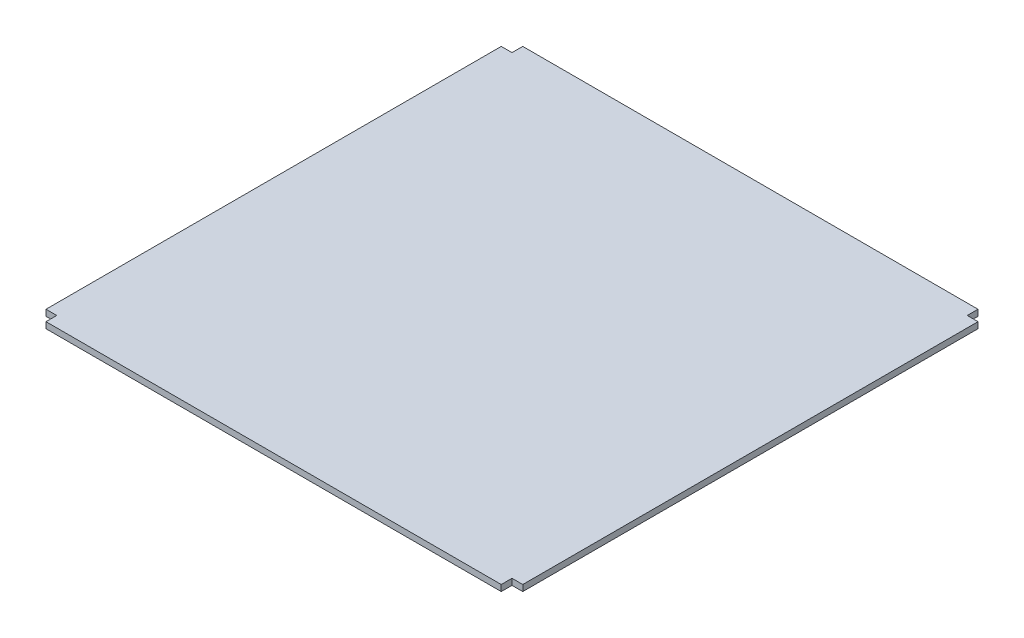
from build123d import *

# Parameters (mm, degrees)
SKETCH_1_W               = 310
SKETCH_1_H               = 310
EXTRUDE_1_DEPTH          = 4
SKETCH_2_W               = 7
SKETCH_2_H               = 7
CUT_EXTRUDE_1_DEPTH      = 6
PATTERN_CIRCULAR_1_COUNT = 4


with BuildPart() as part:
    # 草图1 → 凸台-拉伸1 (new body)
    with BuildSketch(Plane(origin=(0, 0, 0), x_dir=(1, 0, 0), z_dir=(0, 1, 0))):
        Rectangle(SKETCH_1_W, SKETCH_1_H)
    extrude(amount=EXTRUDE_1_DEPTH)

    # 草图2 → 切除-拉伸1 (cut)
    with BuildSketch(Plane(origin=(0, 4, 0), x_dir=(1, 0, 0), z_dir=(0, 1, 0))):
        with Locations((151.5, -151.5)):
            Rectangle(SKETCH_2_W, SKETCH_2_H)
    cut_extrude_1 = extrude(amount=-CUT_EXTRUDE_1_DEPTH, mode=Mode.SUBTRACT)

    # 阵列(圆周)1: 切除-拉伸1 ×4 about axis
    pattern_circular_1_axis = Axis((0, 0, 0), (0, 1, 0))
    for i in range(1, PATTERN_CIRCULAR_1_COUNT):
        add(cut_extrude_1.rotate(pattern_circular_1_axis, i * 360 / PATTERN_CIRCULAR_1_COUNT), mode=Mode.SUBTRACT)


solid = part.part
